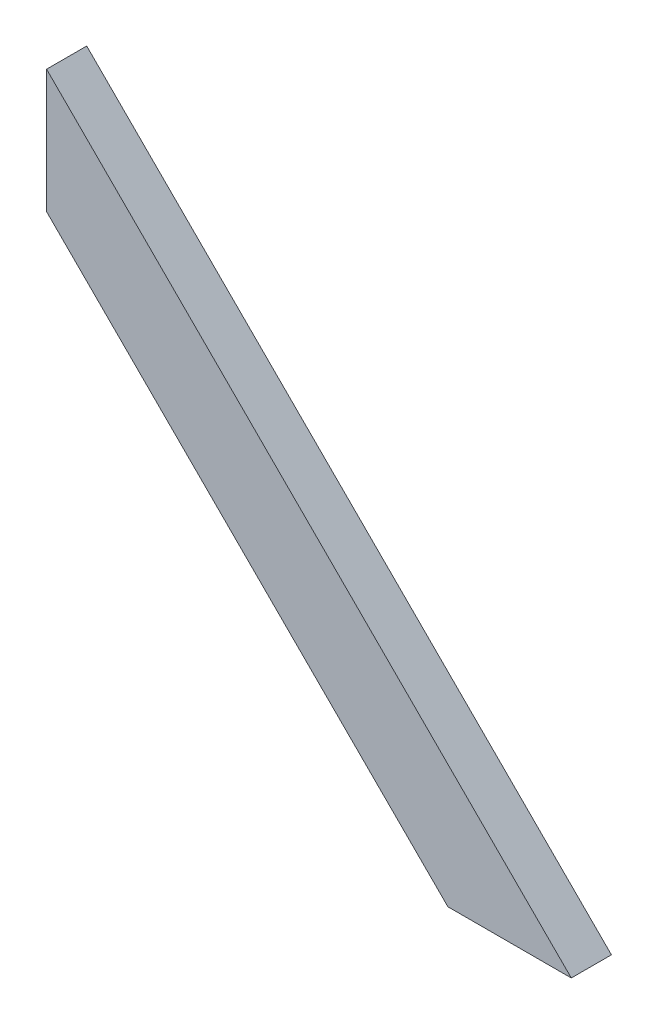
from build123d import *

# Parameters (mm, degrees)
BOSS_EXTRUDE1_DEPTH = 23


with BuildPart() as part:
    # Sketch1 → Boss-Extrude1 (new body)
    with BuildSketch(Plane.XY):
        Polygon((0, 131.506084972), (230, -98.493915028), (300.710678119, -98.493915028), (0, 202.216763091), align=None)
    extrude(amount=BOSS_EXTRUDE1_DEPTH)


solid = part.part
